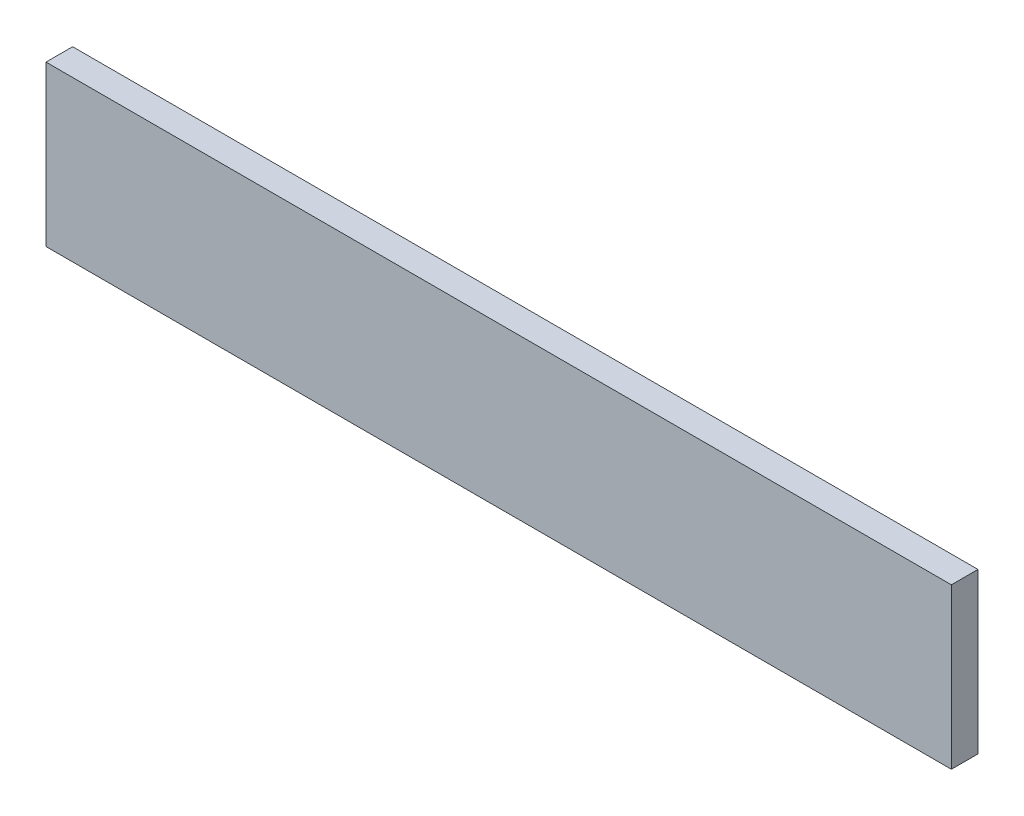
from build123d import *

# Parameters (mm, degrees)
SKETCH1_W           = 215.9
SKETCH1_H           = 38.1
BOSS_EXTRUDE1_DEPTH = 6.35


with BuildPart() as part:
    # Sketch1 → Boss-Extrude1 (new body)
    with BuildSketch(Plane.XY):
        with Locations((107.95, 19.05)):
            Rectangle(SKETCH1_W, SKETCH1_H)
    extrude(amount=BOSS_EXTRUDE1_DEPTH)


solid = part.part
